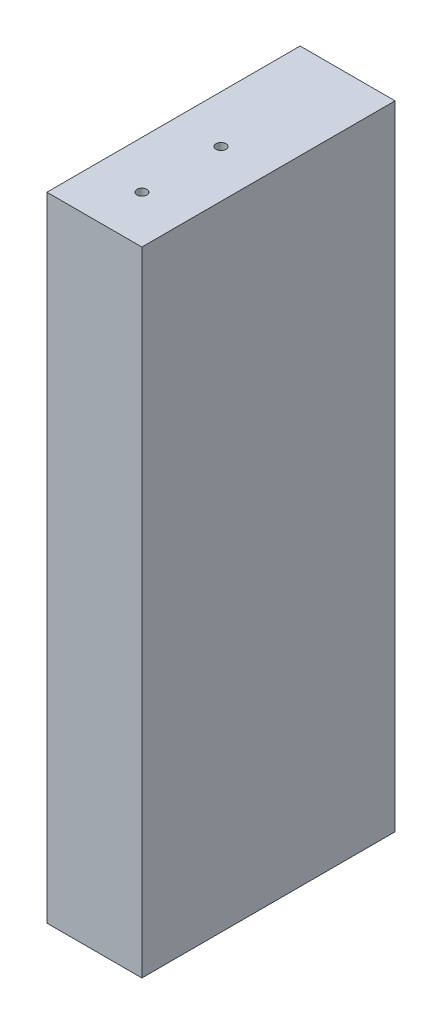
from build123d import *

# Parameters (mm, degrees)
SKETCH1_W                           = 19.05
SKETCH1_H                           = 126.999999888
BOSS_EXTRUDE1_DEPTH                 = 50.8
F_5_64_0_07813_DIAMETER_HOLE1_D     = 1.984502
F_5_64_0_07813_DIAMETER_HOLE1_DEPTH = 38.1
F_5_64_0_07813_DIAMETER_HOLE1_TIP   = 0.59620455
F_5_64_0_07813_DIAMETER_HOLE6_D     = 1.984502
F_5_64_0_07813_DIAMETER_HOLE6_DEPTH = 19.05
F_5_64_0_07813_DIAMETER_HOLE6_TIP   = 0.59620455
F_5_64_0_07813_DIAMETER_HOLE7_D     = 1.984502
F_5_64_0_07813_DIAMETER_HOLE7_DEPTH = 19.05
F_5_64_0_07813_DIAMETER_HOLE7_TIP   = 0.59620455


with BuildPart() as part:
    # Sketch1 → Boss-Extrude1 (new body)
    with BuildSketch(Plane.XY):
        with Locations((377.144680647, 6006.134818763)):
            Rectangle(SKETCH1_W, SKETCH1_H)
    extrude(amount=BOSS_EXTRUDE1_DEPTH)

    # 5/64 (0.07813) Diameter Hole1
    with Locations(Plane(origin=(-83.853965539, -12.395181178, -19.050087596), x_dir=(-1, 0, 0), z_dir=(0, 0, -1))):
        with Locations((-481.589248274, 6993.254992531), (-386.339248274, 6993.254992531), (-291.089248274, 6993.254992531), (-295.274999999, 6965.135938475), (-295.274999999, 6812.735938475), (-295.274999999, 6660.335938474), (-285.166362357, 6631.468843414), (-475.477307398, 6631.468752771), (-485.002307398, 6660.335938474), (-485.002307398, 6812.735938474), (-485.002307398, 6965.135938474), (-478.365617646, 6611.6708), (-287.865617646, 6611.6708), (-307.975, 6564.3379), (-307.975, 6488.1379), (-284.960913066, 6440.805), (-380.210913066, 6440.805), (-475.460913066, 6440.805), (-446.831312422, 6488.1379), (-446.831312422, 6564.3379), (-472.231312422, 6396.355), (-472.231312422, 6320.155), (-472.653156211, 6275.705000839), (-377.403156211, 6275.705000839), (-282.153156211, 6275.705000839), (-282.575, 6320.155), (-282.575, 6396.355), (-435.598646187, 6221.729999816), (-435.598646187, 6145.529999816), (-450.592518112, 6091.554999951), (-460.998646187, 6091.555478285), (-460.998646187, 6056.629999944), (-460.998646187, 5980.429999944), (-460.998646187, 5945.505000042), (-282.153156211, 5945.505000042), (-368.611823093, 5945.505000042)):
            Hole(F_5_64_0_07813_DIAMETER_HOLE1_D / 2, depth=F_5_64_0_07813_DIAMETER_HOLE1_DEPTH)
            with Locations((0, 0, -(F_5_64_0_07813_DIAMETER_HOLE1_DEPTH + F_5_64_0_07813_DIAMETER_HOLE1_TIP / 2))):  # 118° drill point
                Cone(0, F_5_64_0_07813_DIAMETER_HOLE1_D / 2, F_5_64_0_07813_DIAMETER_HOLE1_TIP, mode=Mode.SUBTRACT)

    # 5/64 (0.07813) Diameter Hole6
    with Locations(Plane(origin=(0, 5942.634818819, 0), x_dir=(-1, 0, 0), z_dir=(0, -1, 0))):
        with Locations((-377.144680647, -41.274997961), (-377.144680647, -25.399997961)):
            Hole(F_5_64_0_07813_DIAMETER_HOLE6_D / 2, depth=F_5_64_0_07813_DIAMETER_HOLE6_DEPTH)
            with Locations((0, 0, -(F_5_64_0_07813_DIAMETER_HOLE6_DEPTH + F_5_64_0_07813_DIAMETER_HOLE6_TIP / 2))):  # 118° drill point
                Cone(0, F_5_64_0_07813_DIAMETER_HOLE6_D / 2, F_5_64_0_07813_DIAMETER_HOLE6_TIP, mode=Mode.SUBTRACT)

    # 5/64 (0.07813) Diameter Hole7
    with Locations(Plane(origin=(0, 6069.634818707, 0), x_dir=(1, 0, 0), z_dir=(0, 1, 0))):
        with Locations((377.144680647, -41.274997961), (377.144680647, -25.399997961)):
            Hole(F_5_64_0_07813_DIAMETER_HOLE7_D / 2, depth=F_5_64_0_07813_DIAMETER_HOLE7_DEPTH)
            with Locations((0, 0, -(F_5_64_0_07813_DIAMETER_HOLE7_DEPTH + F_5_64_0_07813_DIAMETER_HOLE7_TIP / 2))):  # 118° drill point
                Cone(0, F_5_64_0_07813_DIAMETER_HOLE7_D / 2, F_5_64_0_07813_DIAMETER_HOLE7_TIP, mode=Mode.SUBTRACT)


solid = part.part
